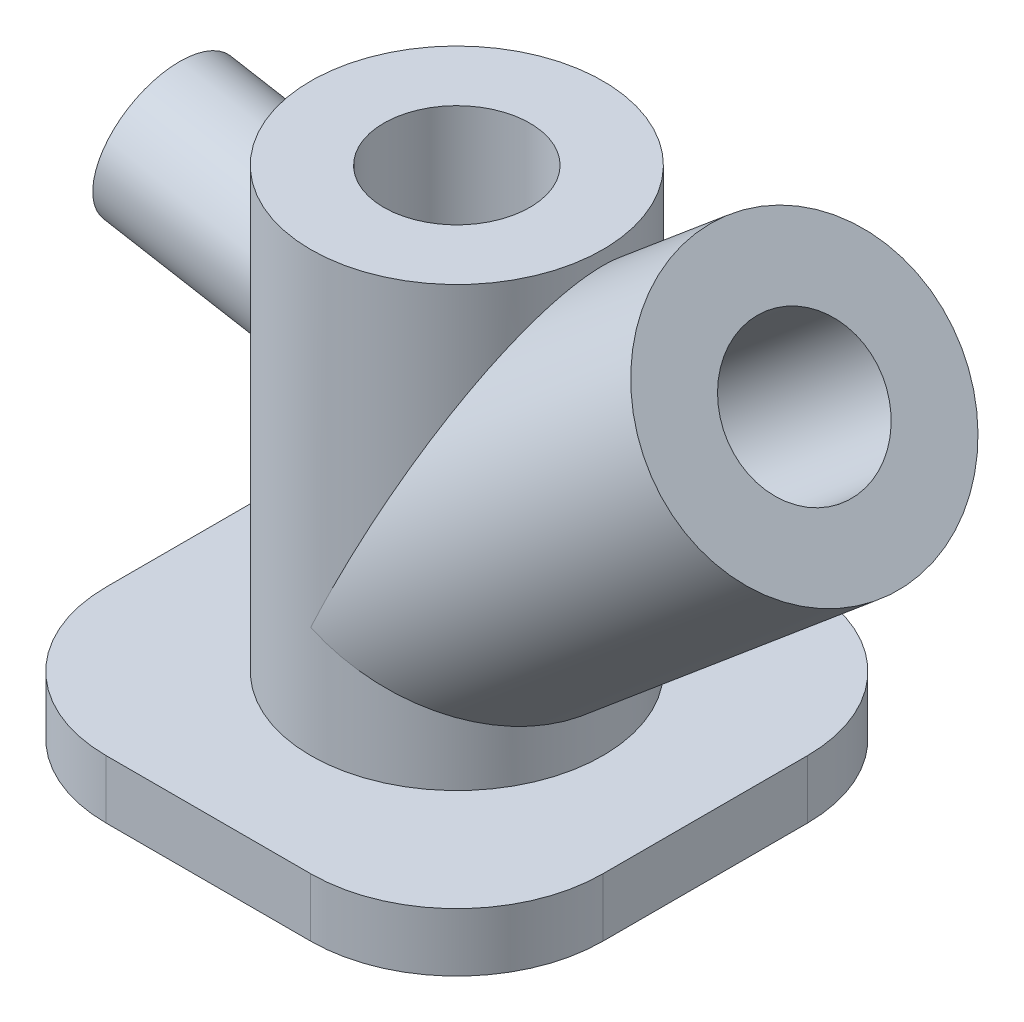
from build123d import *

# Parameters (mm, degrees)
BOSS_EXTRUDE1_DEPTH            = 20
SKETCH3_R                      = 50
BOSS_EXTRUDE2_DEPTH            = 150
SKETCH4_R                      = 25
CUT_EXTRUDE1_DEPTH             = 170
BOSS_EXTRUDE4_REACH            = 259.695
SKETCH6_R                      = 50
CUT_EXTRUDE2_REACH             = 259.695
SKETCH7_R                      = 25
CUT_EXTRUDE2_DIRECTION_2_DEPTH = 50.240387651
BOSS_EXTRUDE5_REACH            = 270.866
SKETCH9_R                      = 25
CUT_EXTRUDE3_REACH             = 270.866
SKETCH10_R                     = 12.5


with BuildPart() as part:
    # Sketch2 → Boss-Extrude1 (new body)
    with BuildSketch(Plane(origin=(0, 0, 0), x_dir=(1, 0, 0), z_dir=(0, 1, 0))):
        with BuildLine():
            Line((35, -85), (-35, -85))
            ThreePointArc((-35, -85), (-70.355339059, -70.355339059), (-85, -35))
            Line((-85, -35), (-85, 35))
            ThreePointArc((-85, 35), (-70.355339059, 70.355339059), (-35, 85))
            Line((-35, 85), (35, 85))
            ThreePointArc((35, 85), (70.355339059, 70.355339059), (85, 35))
            Line((85, 35), (85, -35))
            ThreePointArc((85, -35), (70.355339059, -70.355339059), (35, -85))
        make_face()
    extrude(amount=BOSS_EXTRUDE1_DEPTH)

    # Sketch3 → Boss-Extrude2 (add)
    with BuildSketch(Plane(origin=(0, 20, 0), x_dir=(1, 0, 0), z_dir=(0, 1, 0))):
        Circle(SKETCH3_R)
    extrude(amount=BOSS_EXTRUDE2_DEPTH)

    # Sketch4 → Cut-Extrude1 (cut)
    with BuildSketch(Plane(origin=(0, 170, 0), x_dir=(1, 0, 0), z_dir=(0, 1, 0))):
        Circle(SKETCH4_R)
    extrude(amount=-CUT_EXTRUDE1_DEPTH, mode=Mode.SUBTRACT)

    # Sketch6 → Boss-Extrude4 (add, up to next)
    with BuildSketch(Plane(origin=(147.525591973, 123.788669814, 0), x_dir=(0, 0, -1), z_dir=(0.766044443, 0.64278761, 0)), mode=Mode.PRIVATE) as boss_extrude4_sk1:
        with Locations((0, 44.465063828)):
            Circle(SKETCH6_R)
    boss_extrude4_tool1 = extrude(boss_extrude4_sk1.sketch, amount=-BOSS_EXTRUDE4_REACH, mode=Mode.PRIVATE) - part.part
    add(boss_extrude4_tool1.solids().sort_by_distance((118.944, 157.850885, 0))[0])

    # Sketch7 → Cut-Extrude2 (cut, up to next)
    with BuildSketch(Plane(origin=(147.525591973, 123.788669814, 0), x_dir=(0, 0, -1), z_dir=(0.766044443, 0.64278761, 0)), mode=Mode.PRIVATE) as cut_extrude2_sk1:
        with Locations((0, 44.465063828)):
            Circle(SKETCH7_R)
    cut_extrude2_tool1 = extrude(cut_extrude2_sk1.sketch, amount=-CUT_EXTRUDE2_REACH, mode=Mode.PRIVATE) & part.part
    add(cut_extrude2_tool1.solids().sort_by_distance((118.944, 157.850885, 0))[0], mode=Mode.SUBTRACT)

    # Sketch7 → Cut-Extrude2 direction 2 (cut)
    with BuildSketch(Plane(origin=(147.525591973, 123.788669814, 0), x_dir=(0, 0, -1), z_dir=(0.766044443, 0.64278761, 0))):
        with Locations((0, 44.465063828)):
            Circle(SKETCH7_R)
    extrude(amount=CUT_EXTRUDE2_DIRECTION_2_DEPTH, mode=Mode.SUBTRACT)

    # Sketch9 → Boss-Extrude5 (add, up to next)
    with BuildSketch(Plane(origin=(-118.25391177, 20.851355219, 0), x_dir=(0, 0, -1), z_dir=(0.984807753, -0.173648178, 0)), mode=Mode.PRIVATE) as boss_extrude5_sk1:
        with Locations((0, 109.494521478)):
            Circle(SKETCH9_R)
    boss_extrude5_tool1 = extrude(boss_extrude5_sk1.sketch, amount=BOSS_EXTRUDE5_REACH, mode=Mode.PRIVATE) - part.part
    add(boss_extrude5_tool1.solids().sort_by_distance((-99.240388, 128.682409, 0))[0])

    # Sketch10 → Cut-Extrude3 (cut, up to next)
    with BuildSketch(Plane(origin=(-118.25391177, 20.851355219, 0), x_dir=(0, 0, 1), z_dir=(-0.984807753, 0.173648178, 0)), mode=Mode.PRIVATE) as cut_extrude3_sk1:
        with Locations((0, 109.494521478)):
            Circle(SKETCH10_R)
    cut_extrude3_tool1 = extrude(cut_extrude3_sk1.sketch, amount=-CUT_EXTRUDE3_REACH, mode=Mode.PRIVATE) & part.part
    add(cut_extrude3_tool1.solids().sort_by_distance((-99.240388, 128.682409, 0))[0], mode=Mode.SUBTRACT)


solid = part.part
